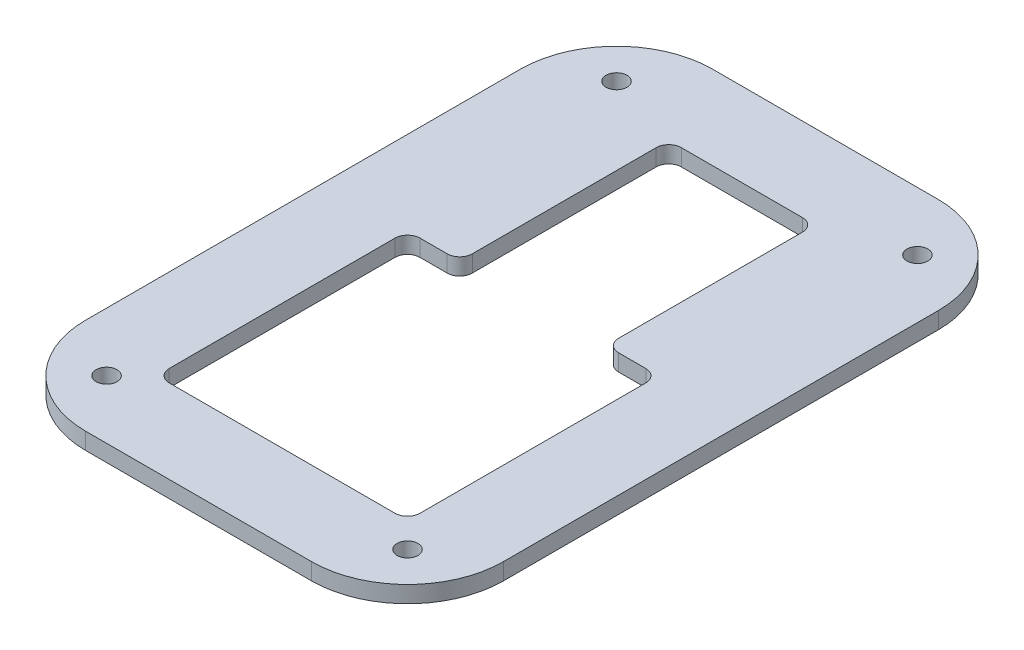
from build123d import *

# Parameters (mm, degrees)
SKETCH1_R           = 2.5
BOSS_EXTRUDE2_DEPTH = 4


with BuildPart() as part:
    # Sketch1 → Boss-Extrude2 (new body)
    with BuildSketch(Plane(origin=(0, 0, 0), x_dir=(1, 0, 0), z_dir=(0, 1, 0))):
        with BuildLine():
            Line((-50, -27), (-50, 77))
            ThreePointArc((-50, 77), (-43.263455967, 93.263455967), (-27, 100))
            Line((-27, 100), (27, 100))
            ThreePointArc((27, 100), (43.263455967, 93.263455967), (50, 77))
            Line((50, 77), (50, -27))
            ThreePointArc((50, -27), (43.263455967, -43.263455967), (27, -50))
            Line((27, -50), (-27, -50))
            ThreePointArc((-27, -50), (-43.263455967, -43.263455967), (-50, -27))
        make_face()
        with Locations((-36, -36)):
            Circle(SKETCH1_R, mode=Mode.SUBTRACT)
        with Locations((-36, 86)):
            Circle(SKETCH1_R, mode=Mode.SUBTRACT)
        with Locations((36, -36)):
            Circle(SKETCH1_R, mode=Mode.SUBTRACT)
        with Locations((36, 86)):
            Circle(SKETCH1_R, mode=Mode.SUBTRACT)
        with BuildLine():
            Line((-27, -30), (27, -30))
            ThreePointArc((27, -30), (29.121320344, -29.121320344), (30, -27))
            Line((30, -27), (30, 27))
            ThreePointArc((30, 27), (29.121320344, 29.121320344), (27, 30))
            Line((27, 30), (20.5, 30))
            ThreePointArc((20.5, 30), (18.378679656, 30.878679656), (17.5, 33))
            Line((17.5, 33), (17.5, 77))
            ThreePointArc((17.5, 77), (16.621320344, 79.121320344), (14.5, 80))
            Line((14.5, 80), (-14.5, 80))
            ThreePointArc((-14.5, 80), (-16.621320344, 79.121320344), (-17.5, 77))
            Line((-17.5, 77), (-17.5, 33))
            ThreePointArc((-17.5, 33), (-18.378679656, 30.878679656), (-20.5, 30))
            Line((-20.5, 30), (-27, 30))
            ThreePointArc((-27, 30), (-29.121320344, 29.121320344), (-30, 27))
            Line((-30, 27), (-30, -27))
            ThreePointArc((-30, -27), (-29.121320344, -29.121320344), (-27, -30))
        make_face(mode=Mode.SUBTRACT)
    extrude(amount=BOSS_EXTRUDE2_DEPTH)


solid = part.part
